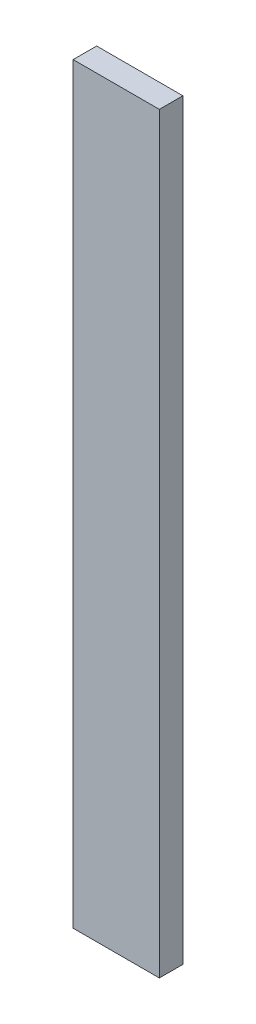
from build123d import *

# Parameters (mm, degrees)
SKETCH1_W           = 139.7
SKETCH1_H           = 38.1
BOSS_EXTRUDE1_DEPTH = 1219.2


with BuildPart() as part:
    # Sketch1 → Boss-Extrude1 (new body)
    with BuildSketch(Plane(origin=(0, 0, 0), x_dir=(1, 0, 0), z_dir=(0, 1, 0))):
        Rectangle(SKETCH1_W, SKETCH1_H)
    extrude(amount=BOSS_EXTRUDE1_DEPTH)


solid = part.part
